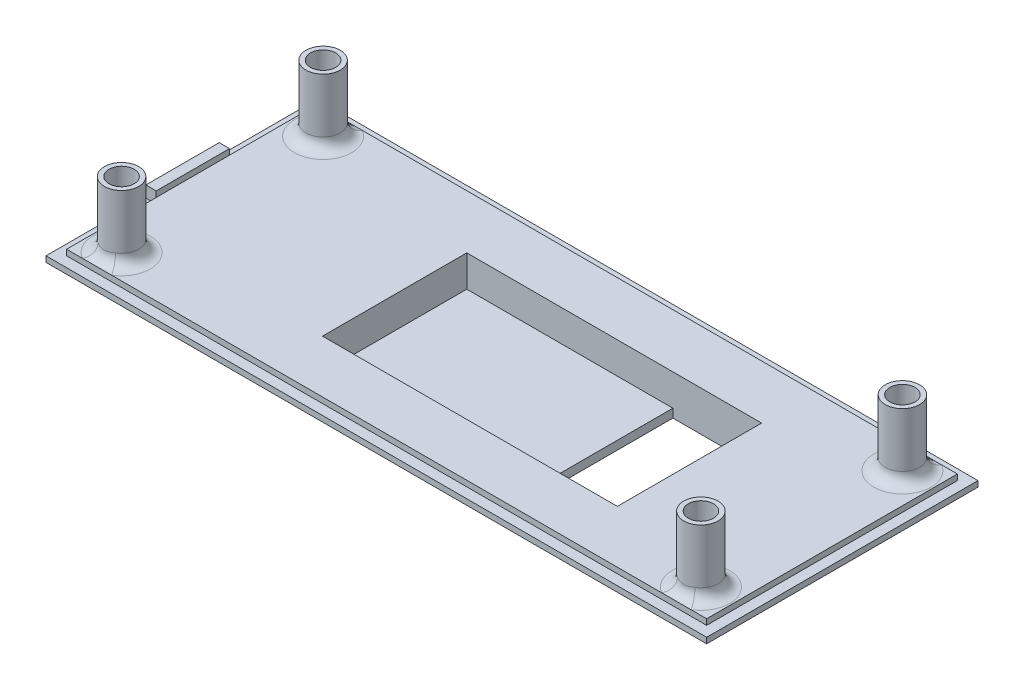
from build123d import *

# Parameters (mm, degrees)
SKETCH_1_W          = 115.4
SKETCH_1_H          = 47.4
EXTRUDE_1_DEPTH     = 1
SKETCH_3_W          = 111.8
SKETCH_3_H          = 43.8
EXTRUDE_3_DEPTH     = 1
SKETCH_10_R         = 3
EXTRUDE_6_DEPTH     = 11.5
CUT_EXTRUDE_4_REACH = 15.5
SKETCH_11_R         = 1.5
SKETCH_12_R         = 2.2
CUT_EXTRUDE_5_DEPTH = 3.5
FILLET_1_R          = 2
FILLET_2_R          = 2
FILLET_3_R          = 2
FILLET_4_R          = 2
CUT_EXTRUDE_6_DEPTH = 2
SKETCH_15_W         = 1.8
SKETCH_15_H         = 12.8
EXTRUDE_8_DEPTH     = 2
SKETCH_16_W         = 54.5
SKETCH_16_H         = 28.2
EXTRUDE_9_DEPTH     = 5
SKETCH_18_W         = 51.5
SKETCH_18_H         = 25.2
CUT_EXTRUDE_7_DEPTH = 5.5
CUT_EXTRUDE_8_REACH = 3.5
SKETCH_19_W         = 15.5
SKETCH_19_H         = 25.2
SKETCH_20_W         = 1.6
SKETCH_20_H         = 10
CUT_EXTRUDE_9_DEPTH = 5
FILLET_5_R          = 2
FILLET_6_R          = 3


with BuildPart() as part:
    # 草图1 → 凸台-拉伸1 (new body)
    with BuildSketch(Plane(origin=(0, 0, 0), x_dir=(1, 0, 0), z_dir=(0, 1, 0))):
        Rectangle(SKETCH_1_W, SKETCH_1_H)
    extrude(amount=EXTRUDE_1_DEPTH)

    # 草图3 → 凸台-拉伸3 (add)
    with BuildSketch(Plane(origin=(0, 1, 0), x_dir=(1, 0, 0), z_dir=(0, 1, 0))):
        Rectangle(SKETCH_3_W, SKETCH_3_H)
    extrude(amount=EXTRUDE_3_DEPTH)

    # 草图10 → 凸台-拉伸6 (add)
    with BuildSketch(Plane(origin=(0, 2, 0), x_dir=(1, 0, 0), z_dir=(0, 1, 0))):
        with Locations((-50.6, 17.6)):
            Circle(SKETCH_10_R)
        with Locations((50.6, 17.6)):
            Circle(SKETCH_10_R)
        with Locations((-50.6, -17.6)):
            Circle(SKETCH_10_R)
        with Locations((50.6, -17.6)):
            Circle(SKETCH_10_R)
    extrude(amount=EXTRUDE_6_DEPTH)

    # 草图11 → 切除-拉伸4 (cut, up to next)
    with BuildSketch(Plane(origin=(0, 13.5, 0), x_dir=(1, 0, 0), z_dir=(0, 1, 0)), mode=Mode.PRIVATE) as cut_extrude_4_sk1:
        with Locations((-50.6, 17.6)):
            Circle(SKETCH_11_R)
    cut_extrude_4_tool1 = extrude(cut_extrude_4_sk1.sketch, amount=-CUT_EXTRUDE_4_REACH, mode=Mode.PRIVATE) & part.part
    add(cut_extrude_4_tool1.solids().sort_by_distance((-50.6, 13.5, -17.6))[0], mode=Mode.SUBTRACT)
    # 草图11 → 切除-拉伸4 (cut, up to next)
    with BuildSketch(Plane(origin=(0, 13.5, 0), x_dir=(1, 0, 0), z_dir=(0, 1, 0)), mode=Mode.PRIVATE) as cut_extrude_4_sk2:
        with Locations((-50.6, -17.6)):
            Circle(SKETCH_11_R)
    cut_extrude_4_tool2 = extrude(cut_extrude_4_sk2.sketch, amount=-CUT_EXTRUDE_4_REACH, mode=Mode.PRIVATE) & part.part
    add(cut_extrude_4_tool2.solids().sort_by_distance((-50.6, 13.5, 17.6))[0], mode=Mode.SUBTRACT)
    # 草图11 → 切除-拉伸4 (cut, up to next)
    with BuildSketch(Plane(origin=(0, 13.5, 0), x_dir=(1, 0, 0), z_dir=(0, 1, 0)), mode=Mode.PRIVATE) as cut_extrude_4_sk3:
        with Locations((50.6, 17.6)):
            Circle(SKETCH_11_R)
    cut_extrude_4_tool3 = extrude(cut_extrude_4_sk3.sketch, amount=-CUT_EXTRUDE_4_REACH, mode=Mode.PRIVATE) & part.part
    add(cut_extrude_4_tool3.solids().sort_by_distance((50.6, 13.5, -17.6))[0], mode=Mode.SUBTRACT)
    # 草图11 → 切除-拉伸4 (cut, up to next)
    with BuildSketch(Plane(origin=(0, 13.5, 0), x_dir=(1, 0, 0), z_dir=(0, 1, 0)), mode=Mode.PRIVATE) as cut_extrude_4_sk4:
        with Locations((50.6, -17.6)):
            Circle(SKETCH_11_R)
    cut_extrude_4_tool4 = extrude(cut_extrude_4_sk4.sketch, amount=-CUT_EXTRUDE_4_REACH, mode=Mode.PRIVATE) & part.part
    add(cut_extrude_4_tool4.solids().sort_by_distance((50.6, 13.5, 17.6))[0], mode=Mode.SUBTRACT)

    # 草图12 → 切除-拉伸5 (cut)
    with BuildSketch(Plane(origin=(0, 13.5, 0), x_dir=(1, 0, 0), z_dir=(0, 1, 0))):
        with Locations((-50.6, 17.6)):
            Circle(SKETCH_12_R)
        with Locations((-50.6, -17.6)):
            Circle(SKETCH_12_R)
        with Locations((50.6, 17.6)):
            Circle(SKETCH_12_R)
        with Locations((50.6, -17.6)):
            Circle(SKETCH_12_R)
    extrude(amount=-CUT_EXTRUDE_5_DEPTH, mode=Mode.SUBTRACT)

    # 圆角1
    fillet_1_edges = [part.edges().sort_by_distance(p)[0] for p in [
        (-53.6, 2, -17.6),
    ]]
    fillet(fillet_1_edges, radius=FILLET_1_R)

    # 圆角2
    fillet_2_edges = [part.edges().sort_by_distance(p)[0] for p in [
        (-53.6, 2, 17.6),
    ]]
    fillet(fillet_2_edges, radius=FILLET_2_R)

    # 圆角3
    fillet_3_edges = [part.edges().sort_by_distance(p)[0] for p in [
        (47.6, 2, 17.6),
    ]]
    fillet(fillet_3_edges, radius=FILLET_3_R)

    # 圆角4
    fillet_4_edges = [part.edges().sort_by_distance(p)[0] for p in [
        (47.6, 2, -17.6),
    ]]
    fillet(fillet_4_edges, radius=FILLET_4_R)

    # 草图13 → 切除-拉伸6 (cut)
    with BuildSketch(Plane.XZ):
        Polygon((53.828799087, -17.432101847), (52.068995478, -14.71982889), (48.840196391, -14.887727044), (47.371200913, -17.767898153), (49.131004522, -20.48017111), (52.359803609, -20.312272956), align=None)
        Polygon((53.829651644, 17.449389261), (52.345258548, 20.321654999), (49.115606904, 20.472265738), (47.370348356, 17.750610739), (48.854741452, 14.878345001), (52.084393096, 14.727734262), align=None)
        Polygon((-47.374682269, -17.374924745), (-49.182262024, -14.694255282), (-52.407579754, -14.919330538), (-53.825317731, -17.825075255), (-52.017737976, -20.505744718), (-48.792420246, -20.280669462), align=None)
        Polygon((-47.373922552, 17.386089661), (-48.801709489, 20.286909855), (-52.027786937, 20.500820194), (-53.826077448, 17.813910339), (-52.398290511, 14.913090145), (-49.172213063, 14.699179806), align=None)
    extrude(amount=-CUT_EXTRUDE_6_DEPTH, mode=Mode.SUBTRACT)

    # 草图15 → 凸台-拉伸8 (add)
    with BuildSketch(Plane(origin=(0, 1, 0), x_dir=(1, 0, 0), z_dir=(0, 1, 0))):
        with Locations((-56.8, 0.15)):
            Rectangle(SKETCH_15_W, SKETCH_15_H)
    extrude(amount=EXTRUDE_8_DEPTH)

    # 草图16 → 凸台-拉伸9 (add)
    with BuildSketch(Plane.XZ):
        with Locations((5.45, 0)):
            Rectangle(SKETCH_16_W, SKETCH_16_H)
    extrude(amount=EXTRUDE_9_DEPTH)

    # 草图18 → 切除-拉伸7 (cut)
    with BuildSketch(Plane(origin=(0, 2, 0), x_dir=(1, 0, 0), z_dir=(0, 1, 0))):
        with Locations((5.35, -0.1)):
            Rectangle(SKETCH_18_W, SKETCH_18_H)
    extrude(amount=-CUT_EXTRUDE_7_DEPTH, mode=Mode.SUBTRACT)

    # 草图19 → 切除-拉伸8 (cut, up to next)
    with BuildSketch(Plane(origin=(0, -3.5, 0), x_dir=(1, 0, 0), z_dir=(0, 1, 0)), mode=Mode.PRIVATE) as cut_extrude_8_sk1:
        with Locations((23.35, -0.1)):
            Rectangle(SKETCH_19_W, SKETCH_19_H)
    cut_extrude_8_tool1 = extrude(cut_extrude_8_sk1.sketch, amount=-CUT_EXTRUDE_8_REACH, mode=Mode.PRIVATE) & part.part
    add(cut_extrude_8_tool1.solids().sort_by_distance((23.35, -3.5, 0.1))[0], mode=Mode.SUBTRACT)

    # 草图20 → 切除-拉伸9 (cut)
    with BuildSketch(Plane.XZ.offset(5)):
        with Locations((31.9, 0.1)):
            Rectangle(SKETCH_20_W, SKETCH_20_H)
    extrude(amount=-CUT_EXTRUDE_9_DEPTH, mode=Mode.SUBTRACT)

    # 圆角5
    fillet_5_edges = [part.edges().sort_by_distance(p)[0] for p in [
        (31.9, 0, 5.1),
        (31.9, 0, -4.9),
    ]]
    fillet(fillet_5_edges, radius=FILLET_5_R)

    # 圆角6
    fillet_6_edges = [part.edges().sort_by_distance(p)[0] for p in [
        (-21.8, 0, 0),
        (5.45, 0, -14.1),
        (32.7, 0, -9.5),
        (5.45, 0, 14.1),
        (32.7, 0, 9.6),
    ]]
    fillet(fillet_6_edges, radius=FILLET_6_R)


solid = part.part
